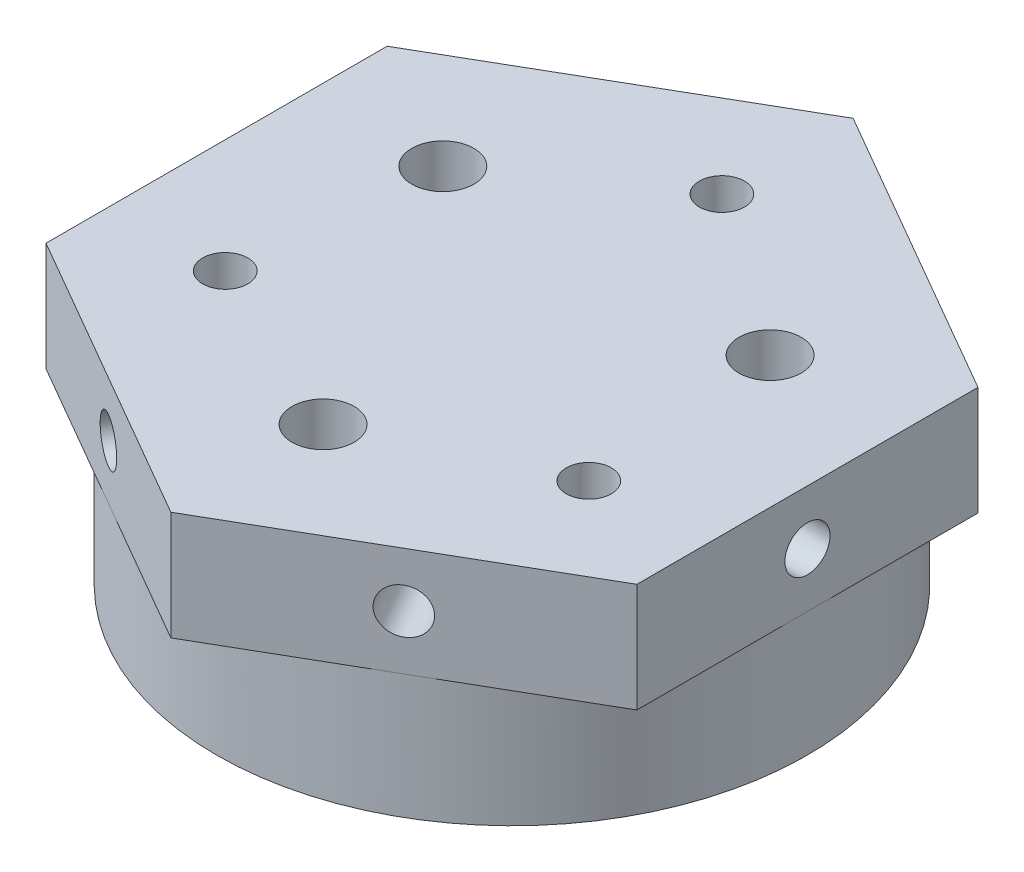
from build123d import *

# Parameters (mm, degrees)
SKETCH_1_R          = 19
SKETCH_1_R_2        = 1.45
SKETCH_1_R_3        = 2
EXTRUDE_1_DEPTH     = 15
SKETCH_2_R          = 1.45
SKETCH_2_R_2        = 2
EXTRUDE_2_DEPTH     = 7
SKETCH_3_R          = 1.45
CUT_EXTRUDE_1_DEPTH = 8
SKETCH_4_R          = 1.45
CUT_EXTRUDE_2_DEPTH = 8
SKETCH_5_R          = 1.45
CUT_EXTRUDE_3_DEPTH = 8
SKETCH_6_R          = 1.45
CUT_EXTRUDE_4_DEPTH = 8
SKETCH_7_R          = 1.45
CUT_EXTRUDE_5_DEPTH = 8


with BuildPart() as part:
    # 草图1 → 凸台-拉伸1 (new body)
    with BuildSketch(Plane(origin=(0, 0, 0), x_dir=(1, 0, 0), z_dir=(0, 1, 0))):
        Circle(SKETCH_1_R)
        with Locations((0, 13.5)):
            Circle(SKETCH_1_R_2, mode=Mode.SUBTRACT)
        with Locations((-11.691342951, -6.75)):
            Circle(SKETCH_1_R_2, mode=Mode.SUBTRACT)
        with Locations((11.691342951, -6.75)):
            Circle(SKETCH_1_R_2, mode=Mode.SUBTRACT)
        with Locations((-10.522208656, 6.075)):
            Circle(SKETCH_1_R_3, mode=Mode.SUBTRACT)
        with Locations((0, -12.15)):
            Circle(SKETCH_1_R_3, mode=Mode.SUBTRACT)
        with Locations((10.522208656, 6.075)):
            Circle(SKETCH_1_R_3, mode=Mode.SUBTRACT)
    extrude(amount=EXTRUDE_1_DEPTH)

    # 草图2 → 凸台-拉伸2 (add)
    with BuildSketch(Plane(origin=(0, 15, 0), x_dir=(1, 0, 0), z_dir=(0, 1, 0))):
        Polygon((0, 21.939310229), (-19, 10.969655115), (-19, -10.969655115), (0, -21.939310229), (19, -10.969655115), (19, 10.969655115), align=None)
        with Locations((0, 13.5)):
            Circle(SKETCH_2_R, mode=Mode.SUBTRACT)
        with Locations((-10.522208656, 6.075)):
            Circle(SKETCH_2_R_2, mode=Mode.SUBTRACT)
        with Locations((10.522208656, 6.075)):
            Circle(SKETCH_2_R_2, mode=Mode.SUBTRACT)
        with Locations((-11.691342951, -6.75)):
            Circle(SKETCH_2_R, mode=Mode.SUBTRACT)
        with Locations((0, -12.15)):
            Circle(SKETCH_2_R_2, mode=Mode.SUBTRACT)
        with Locations((11.691342951, -6.75)):
            Circle(SKETCH_2_R, mode=Mode.SUBTRACT)
    extrude(amount=-EXTRUDE_2_DEPTH)

    # 草图3 → 切除-拉伸1 (cut)
    with BuildSketch(Plane(origin=(9.5, 0, 16.454482672), x_dir=(0.866025404, 0, -0.5), z_dir=(0.5, 0, 0.866025404))):
        with Locations((0, 11.5)):
            Circle(SKETCH_3_R)
    extrude(amount=-CUT_EXTRUDE_1_DEPTH, mode=Mode.SUBTRACT)

    # 草图4 → 切除-拉伸2 (cut)
    with BuildSketch(Plane(origin=(-9.5, 0, 16.454482672), x_dir=(0.866025404, 0, 0.5), z_dir=(-0.5, 0, 0.866025404))):
        with Locations((0, 11.5)):
            Circle(SKETCH_4_R)
    extrude(amount=-CUT_EXTRUDE_2_DEPTH, mode=Mode.SUBTRACT)

    # 草图5 → 切除-拉伸3 (cut)
    with BuildSketch(Plane.ZY.offset(19)):
        with Locations((0, 11.5)):
            Circle(SKETCH_5_R)
    extrude(amount=-CUT_EXTRUDE_3_DEPTH, mode=Mode.SUBTRACT)

    # 草图6 → 切除-拉伸4 (cut)
    with BuildSketch(Plane(origin=(19, 0, 0), x_dir=(0, 0, -1), z_dir=(1, 0, 0))):
        with Locations((0, 11.5)):
            Circle(SKETCH_6_R)
    extrude(amount=-CUT_EXTRUDE_4_DEPTH, mode=Mode.SUBTRACT)

    # 草图7 → 切除-拉伸5 (cut)
    with BuildSketch(Plane(origin=(9.5, 0, -16.454482672), x_dir=(-0.866025404, 0, -0.5), z_dir=(0.5, 0, -0.866025404))):
        with Locations((0, 11.5)):
            Circle(SKETCH_7_R)
    extrude(amount=-CUT_EXTRUDE_5_DEPTH, mode=Mode.SUBTRACT)


solid = part.part
